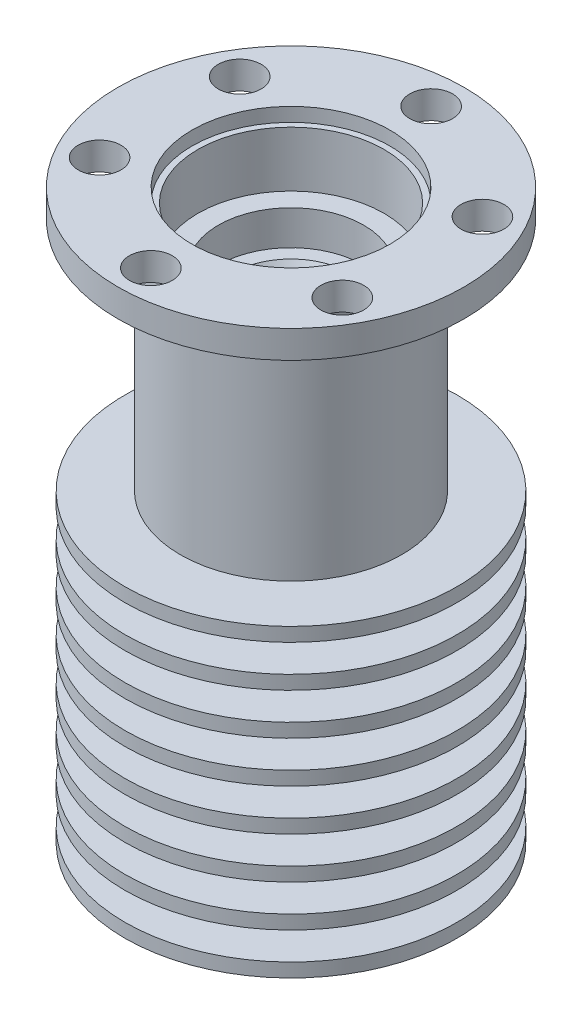
from build123d import *

# Parameters (mm, degrees)
CROQUIS3_R              = 12
CROQUIS3_R_2            = 3.25
SALIENTE_EXTRUIR1_DEPTH = 1
MATRIZL1_COUNT          = 8
MATRIZL1_PITCH          = 3
CROQUIS5_R              = 1.55
CORTAR_EXTRUIR1_DEPTH   = 2
MATRIZC1_COUNT          = 6
CHAFL_N3_SIZE           = 0.3
CHAFL_N3_SIZE2          = 0.519615242
CROQUIS6_R              = 7.15
CORTAR_EXTRUIR2_DEPTH   = 1
CHAFL_N2_SIZE           = 0.15
CHAFL_N2_SIZE2          = 0.259807621
CHAFL_N4_SIZE           = 1
CHAFL_N4_SIZE2          = 1.732050808


with BuildPart() as part:
    # Croquis1 → Revolución1 (revolve)
    with BuildSketch(Plane.XY):
        Polygon((0, 0), (6, 0), (6, 9), (5.25, 9), (5.25, 12), (4.75, 12), (4.75, 22), (8, 22), (8, 39), (12.5, 39), (12.5, 41), (0, 41), align=None)
    revolve(axis=Axis((0, 41, 0), (0, -1, 0)))

    # Croquis2 → Cortar-Revolución1 (revolve, cut)
    with BuildSketch(Plane.XY):
        Polygon((0, 0), (2.5, 0), (2.5, 12), (1.7, 12), (1.7, 14), (3.25, 14), (3.25, 33.5), (5.25, 33.5), (5.25, 36), (6.725, 36), (6.725, 41), (0, 41), align=None)
    revolve(axis=Axis((0, 0, 0), (0, 1, 0)), mode=Mode.SUBTRACT)

    # Croquis3 → Saliente-Extruir1 (add)
    with BuildSketch(Plane.XZ):
        Circle(CROQUIS3_R)
        Circle(CROQUIS3_R_2, mode=Mode.SUBTRACT)
    saliente_extruir1 = extrude(amount=-SALIENTE_EXTRUIR1_DEPTH)

    # MatrizL1: Saliente-Extruir1 ×8
    with Locations(*[(0, i * MATRIZL1_PITCH, 0) for i in range(1, MATRIZL1_COUNT)]):
        add(saliente_extruir1)

    # Croquis5 → Cortar-Extruir1 (cut)
    with BuildSketch(Plane(origin=(0, 41, 0), x_dir=(1, 0, 0), z_dir=(0, 1, 0))):
        with Locations((0, 10.125)):
            Circle(CROQUIS5_R)
    cortar_extruir1 = extrude(amount=-CORTAR_EXTRUIR1_DEPTH, mode=Mode.SUBTRACT)

    # MatrizC1: Cortar-Extruir1 ×6 about axis
    matrizc1_axis = Axis((0, 0, 0), (0, 1, 0))
    for i in range(1, MATRIZC1_COUNT):
        add(cortar_extruir1.rotate(matrizc1_axis, i * 360 / MATRIZC1_COUNT), mode=Mode.SUBTRACT)

    # Chaflán3
    chafl_n3_edges = [part.edges().sort_by_distance(p)[0] for p in [
        (-1.7, 14, 0),
    ]]
    chafl_n3_side = [part.faces().sort_by_distance(p)[0] for p in [
        (-1.791923882, 14, 0),
    ]]
    chamfer(chafl_n3_edges, length=CHAFL_N3_SIZE, length2=CHAFL_N3_SIZE2, reference=chafl_n3_side[0])

    # Croquis6 → Cortar-Extruir2 (cut)
    with BuildSketch(Plane(origin=(0, 41, 0), x_dir=(1, 0, 0), z_dir=(0, 1, 0))):
        Circle(CROQUIS6_R)
    extrude(amount=-CORTAR_EXTRUIR2_DEPTH, mode=Mode.SUBTRACT)

    # Chaflán2
    chafl_n2_edges = [part.edges().sort_by_distance(p)[0] for p in [
        (-1.7, 12, 0),
    ]]
    chafl_n2_side = [part.faces().sort_by_distance(p)[0] for p in [
        (-2.429289322, 12, 0),
    ]]
    chamfer(chafl_n2_edges, length=CHAFL_N2_SIZE, length2=CHAFL_N2_SIZE2, reference=chafl_n2_side[0])

    # Chaflán4
    chafl_n4_edges = [part.edges().sort_by_distance(p)[0] for p in [
        (-3.25, 33.5, 0),
    ]]
    chafl_n4_side = [part.faces().sort_by_distance(p)[0] for p in [
        (-3.398492424, 33.5, 0),
    ]]
    chamfer(chafl_n4_edges, length=CHAFL_N4_SIZE, length2=CHAFL_N4_SIZE2, reference=chafl_n4_side[0])


solid = part.part
